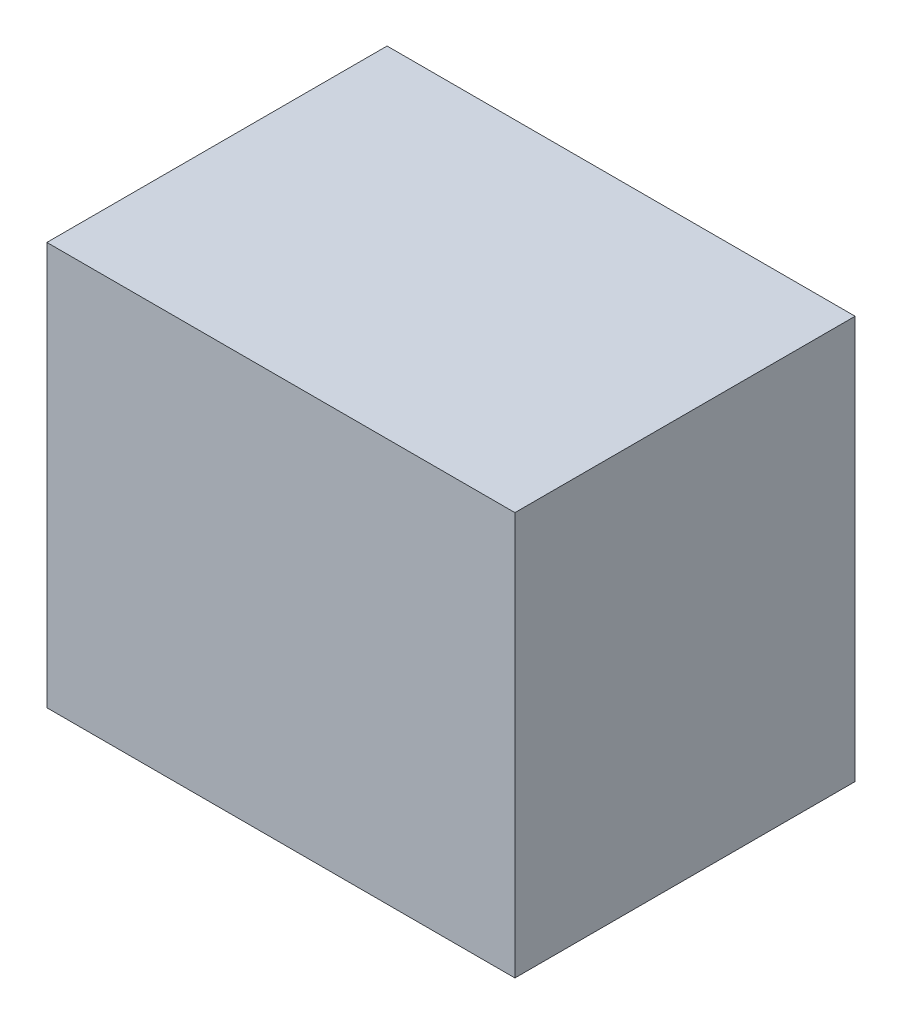
from build123d import *

# Parameters (mm, degrees)
SKETCH1_W           = 54
SKETCH1_H           = 39.25
BOSS_EXTRUDE1_DEPTH = 46.5


with BuildPart() as part:
    # Sketch1 → Boss-Extrude1 (new body)
    with BuildSketch(Plane(origin=(0, 0, 0), x_dir=(1, 0, 0), z_dir=(0, 1, 0))):
        with Locations((27, 19.625)):
            Rectangle(SKETCH1_W, SKETCH1_H)
    extrude(amount=BOSS_EXTRUDE1_DEPTH)


solid = part.part
